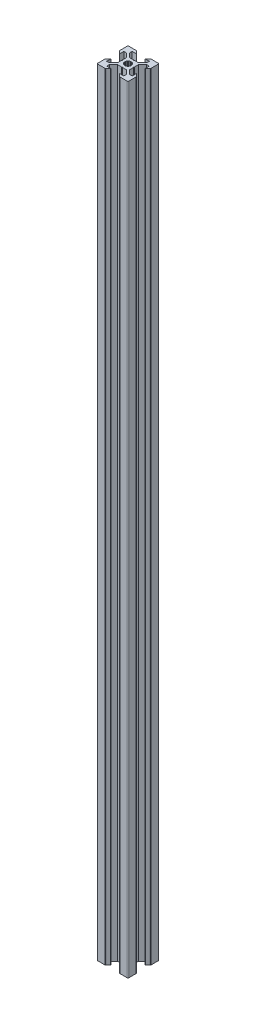
from build123d import *

# Parameters (mm, degrees)
SALIENTE_EXTRUIR1_DEPTH = 500


with BuildPart() as part:
    # Croquis1 → Saliente-Extruir1 (new body)
    with BuildSketch(Plane(origin=(0, 0, 0), x_dir=(1, 0, 0), z_dir=(0, 1, 0))):
        with BuildLine():
            Line((827.4236778, 71.014633494), (827.419784138, 71.054166508))
            Line((827.419784138, 71.054166508), (827.418484267, 71.162420688))
            Line((827.418484267, 71.162420688), (827.418484196, 74.762420877))
            Line((827.418484196, 74.762420877), (827.418484121, 75.762420899))
            ThreePointArc((827.418484121, 75.762420899), (827.564930731, 76.11597429), (827.918484121, 76.262420899))
            Line((827.918484121, 76.262420899), (828.918484173, 76.262420899))
            Line((828.918484173, 76.262420899), (832.587035917, 76.262421281))
            Line((832.587035917, 76.262421281), (832.626738946, 76.261121539))
            Line((832.626738946, 76.261121539), (832.66627196, 76.257227878))
            Line((832.66627196, 76.257227878), (832.705465673, 76.25075697))
            Line((832.705465673, 76.25075697), (832.744152252, 76.241736525))
            Line((832.744152252, 76.241736525), (832.782166034, 76.230205171))
            Line((832.782166034, 76.230205171), (832.81934424, 76.216212285))
            Line((832.81934424, 76.216212285), (832.855527665, 76.199817789))
            Line((832.855527665, 76.199817789), (832.890561368, 76.181091885))
            Line((832.890561368, 76.181091885), (832.924295328, 76.160114761))
            Line((832.924295328, 76.160114761), (832.956585091, 76.136976243))
            Line((832.956585091, 76.136976243), (832.987292389, 76.111775416))
            Line((832.987292389, 76.111775416), (833.016285726, 76.084620192))
            Line((833.016285726, 76.084620192), (834.531857711, 74.569048208))
            Line((834.531857711, 74.569048208), (834.531857711, 74.462421311))
            Line((834.531857711, 74.462421311), (831.918484198, 74.462420944))
            Line((831.918484198, 74.462420944), (831.918484223, 72.823081117))
            Line((831.918484223, 72.823081117), (834.579144475, 70.16242107))
            Line((834.579144475, 70.16242107), (837.213715095, 70.162421031))
            Line((837.213715095, 70.162421031), (837.418484299, 69.957651822))
            Line((837.418484299, 69.957651822), (837.623253509, 70.162421025))
            Line((837.623253509, 70.162421025), (840.257824129, 70.162420986))
            Line((840.257824129, 70.162420986), (842.918484218, 72.823081281))
            Line((842.918484218, 72.823081281), (842.918484194, 74.462421108))
            Line((842.918484194, 74.462421108), (840.305111552, 74.462421165))
            Line((840.305111552, 74.462421165), (840.305111552, 74.569048062))
            Line((840.305111552, 74.569048062), (841.820683537, 76.084620046))
            Line((841.820683537, 76.084620046), (841.849676874, 76.11177527))
            Line((841.849676874, 76.11177527), (841.880384171, 76.136976097))
            Line((841.880384171, 76.136976097), (841.912673935, 76.160114615))
            Line((841.912673935, 76.160114615), (841.946407895, 76.181091739))
            Line((841.946407895, 76.181091739), (841.981441597, 76.199817643))
            Line((841.981441597, 76.199817643), (842.017625023, 76.216212139))
            Line((842.017625023, 76.216212139), (842.054803228, 76.230205025))
            Line((842.054803228, 76.230205025), (842.092817011, 76.241736379))
            Line((842.092817011, 76.241736379), (842.13150359, 76.250756824))
            Line((842.13150359, 76.250756824), (842.170697303, 76.257227732))
            Line((842.170697303, 76.257227732), (842.210230317, 76.261121393))
            Line((842.210230317, 76.261121393), (842.249933345, 76.262421135))
            Line((842.249933345, 76.262421135), (845.918484166, 76.262421152))
            Line((845.918484166, 76.262421152), (846.918484113, 76.262420899))
            ThreePointArc((846.918484113, 76.262420899), (847.272037504, 76.11597429), (847.418484113, 75.762420899))
            Line((847.418484113, 75.762420899), (847.418484676, 71.093869834))
            Line((847.418484676, 71.093869834), (847.417184713, 71.054166625))
            Line((847.417184713, 71.054166625), (847.413291052, 71.014633611))
            Line((847.413291052, 71.014633611), (847.406820144, 70.975439898))
            Line((847.406820144, 70.975439898), (847.397799699, 70.936753319))
            Line((847.397799699, 70.936753319), (847.386268345, 70.898739536))
            Line((847.386268345, 70.898739536), (847.372275459, 70.861561331))
            Line((847.372275459, 70.861561331), (847.355880963, 70.825377905))
            Line((847.355880963, 70.825377905), (847.337155059, 70.790344203))
            Line((847.337155059, 70.790344203), (847.316177935, 70.756610243))
            Line((847.316177935, 70.756610243), (847.293039418, 70.724320479))
            Line((847.293039418, 70.724320479), (847.26783859, 70.693613182))
            Line((847.26783859, 70.693613182), (847.240683366, 70.664619845))
            Line((847.240683366, 70.664619845), (845.725111382, 69.14904786))
            Line((845.725111382, 69.14904786), (845.618484485, 69.14904786))
            Line((845.618484485, 69.14904786), (845.618484322, 71.762420905))
            Line((845.618484322, 71.762420905), (843.979144495, 71.76242093))
            Line((843.979144495, 71.76242093), (841.318484285, 69.101760799))
            Line((841.318484285, 69.101760799), (841.318484245, 66.462288999))
            Line((841.318484245, 66.462288999), (841.118616215, 66.262420975))
            Line((841.118616215, 66.262420975), (841.318484239, 66.062552944))
            Line((841.318484239, 66.062552944), (841.3184842, 63.423081145))
            Line((841.3184842, 63.423081145), (843.979144331, 60.762420934))
            Line((843.979144331, 60.762420934), (845.618484159, 60.76242091))
            Line((845.618484159, 60.76242091), (845.618484631, 63.375794018))
            Line((845.618484631, 63.375794018), (845.725111528, 63.375794018))
            Line((845.725111528, 63.375794018), (847.240683512, 61.860222034))
            Line((847.240683512, 61.860222034), (847.267838736, 61.831228696))
            Line((847.267838736, 61.831228696), (847.293039564, 61.800521399))
            Line((847.293039564, 61.800521399), (847.316178081, 61.768231636))
            Line((847.316178081, 61.768231636), (847.337155205, 61.734497676))
            Line((847.337155205, 61.734497676), (847.355881109, 61.699463973))
            Line((847.355881109, 61.699463973), (847.372275605, 61.663280548))
            Line((847.372275605, 61.663280548), (847.386268491, 61.626102342))
            Line((847.386268491, 61.626102342), (847.397799845, 61.58808856))
            Line((847.397799845, 61.58808856), (847.40682029, 61.549401981))
            Line((847.40682029, 61.549401981), (847.413291198, 61.510208268))
            Line((847.413291198, 61.510208268), (847.417184859, 61.470675254))
            Line((847.417184859, 61.470675254), (847.418484601, 61.430972225))
            Line((847.418484601, 61.430972225), (847.418484113, 57.762420884))
            Line((847.418484113, 57.762420884), (847.418484113, 56.762420907))
            ThreePointArc((847.418484113, 56.762420907), (847.272037504, 56.408867517), (846.918484113, 56.262420907))
            Line((846.918484113, 56.262420907), (845.918484091, 56.262420907))
            Line((845.918484091, 56.262420907), (842.249933271, 56.262420924))
            Line((842.249933271, 56.262420924), (842.210230242, 56.263720666))
            Line((842.210230242, 56.263720666), (842.170697228, 56.267614328))
            Line((842.170697228, 56.267614328), (842.131503515, 56.274085236))
            Line((842.131503515, 56.274085236), (842.092816936, 56.28310568))
            Line((842.092816936, 56.28310568), (842.054803154, 56.294637035))
            Line((842.054803154, 56.294637035), (842.017624948, 56.30862992))
            Line((842.017624948, 56.30862992), (841.981441523, 56.325024417))
            Line((841.981441523, 56.325024417), (841.94640782, 56.343750321))
            Line((841.94640782, 56.343750321), (841.91267386, 56.364727445))
            Line((841.91267386, 56.364727445), (841.880384097, 56.387865962))
            Line((841.880384097, 56.387865962), (841.8496768, 56.41306679))
            Line((841.8496768, 56.41306679), (841.820683462, 56.440222013))
            Line((841.820683462, 56.440222013), (840.305111478, 57.955793998))
            Line((840.305111478, 57.955793998), (840.305111478, 58.062420895))
            Line((840.305111478, 58.062420895), (842.918484119, 58.062420951))
            Line((842.918484119, 58.062420951), (842.918484144, 59.701760779))
            Line((842.918484144, 59.701760779), (840.257824013, 62.362420989))
            Line((840.257824013, 62.362420989), (837.623253392, 62.362421028))
            Line((837.623253392, 62.362421028), (837.418484189, 62.567190238))
            Line((837.418484189, 62.567190238), (837.211510002, 62.362420842))
            Line((837.211510002, 62.362420842), (834.579144359, 62.362421074))
            Line((834.579144359, 62.362421074), (831.918484148, 59.701760943))
            Line((831.918484148, 59.701760943), (831.918484124, 58.062421115))
            Line((831.918484124, 58.062421115), (834.531857636, 58.062420749))
            Line((834.531857636, 58.062420749), (834.531857636, 57.955793852))
            Line((834.531857636, 57.955793852), (833.016285651, 56.440221867))
            Line((833.016285651, 56.440221867), (832.987292314, 56.413066643))
            Line((832.987292314, 56.413066643), (832.956585017, 56.387865816))
            Line((832.956585017, 56.387865816), (832.924295253, 56.364727299))
            Line((832.924295253, 56.364727299), (832.890561293, 56.343750175))
            Line((832.890561293, 56.343750175), (832.855527591, 56.325024271))
            Line((832.855527591, 56.325024271), (832.819344165, 56.308629774))
            Line((832.819344165, 56.308629774), (832.78216596, 56.294636889))
            Line((832.78216596, 56.294636889), (832.744152177, 56.283105534))
            Line((832.744152177, 56.283105534), (832.705465598, 56.27408509))
            Line((832.705465598, 56.27408509), (832.666271885, 56.267614182))
            Line((832.666271885, 56.267614182), (832.626738871, 56.26372052))
            Line((832.626738871, 56.26372052), (832.587035843, 56.262420778))
            Line((832.587035843, 56.262420778), (827.918484121, 56.262420907))
            ThreePointArc((827.918484121, 56.262420907), (827.564930731, 56.408867517), (827.418484121, 56.762420907))
            Line((827.418484121, 56.762420907), (827.418484121, 57.762421182))
            Line((827.418484121, 57.762421182), (827.418484413, 61.362420692))
            Line((827.418484413, 61.362420692), (827.419784284, 61.470675137))
            Line((827.419784284, 61.470675137), (827.423677946, 61.510208151))
            Line((827.423677946, 61.510208151), (827.430148853, 61.549401865))
            Line((827.430148853, 61.549401865), (827.439169298, 61.588088443))
            Line((827.439169298, 61.588088443), (827.450700653, 61.626102226))
            Line((827.450700653, 61.626102226), (827.464693538, 61.663280431))
            Line((827.464693538, 61.663280431), (827.481088034, 61.699463857))
            Line((827.481088034, 61.699463857), (827.499813938, 61.73449756))
            Line((827.499813938, 61.73449756), (827.520791063, 61.76823152))
            Line((827.520791063, 61.76823152), (827.54392958, 61.800521283))
            Line((827.54392958, 61.800521283), (827.569130407, 61.83122858))
            Line((827.569130407, 61.83122858), (827.596285631, 61.860221918))
            Line((827.596285631, 61.860221918), (829.111857616, 63.375793902))
            Line((829.111857616, 63.375793902), (829.218484512, 63.375793902))
            Line((829.218484512, 63.375793902), (829.218484165, 60.762421154))
            Line((829.218484165, 60.762421154), (830.857823993, 60.76242113))
            Line((830.857823993, 60.76242113), (833.518484203, 63.423081261))
            Line((833.518484203, 63.423081261), (833.518484243, 66.06255306))
            Line((833.518484243, 66.06255306), (833.718352273, 66.262421085))
            Line((833.718352273, 66.262421085), (833.518484248, 66.462289116))
            Line((833.518484248, 66.462289116), (833.518484288, 69.101760915))
            Line((833.518484288, 69.101760915), (830.857824157, 71.762421125))
            Line((830.857824157, 71.762421125), (829.218484329, 71.76242115))
            Line((829.218484329, 71.76242115), (829.218484366, 69.149047744))
            Line((829.218484366, 69.149047744), (829.11185747, 69.149047744))
            Line((829.11185747, 69.149047744), (827.596285485, 70.664619728))
            Line((827.596285485, 70.664619728), (827.569130261, 70.693613066))
            Line((827.569130261, 70.693613066), (827.543929434, 70.724320363))
            Line((827.543929434, 70.724320363), (827.520790917, 70.756610126))
            Line((827.520790917, 70.756610126), (827.499813792, 70.790344086))
            Line((827.499813792, 70.790344086), (827.481087888, 70.825377789))
            Line((827.481087888, 70.825377789), (827.464693392, 70.861561215))
            Line((827.464693392, 70.861561215), (827.450700507, 70.89873942))
            Line((827.450700507, 70.89873942), (827.439169152, 70.936753202))
            Line((827.439169152, 70.936753202), (827.430148707, 70.975439781))
            Line((827.430148707, 70.975439781), (827.4236778, 71.014633494))
        make_face()
        Polygon((835.599830933, 65.212420993), (835.933560041, 64.777496752), (836.368484281, 64.443767645), (836.874964286, 64.233976757), (837.418484281, 64.162420993), (837.962004276, 64.233976757), (838.468484281, 64.443767645), (838.903408522, 64.777496752), (839.237137629, 65.212420993), (839.446928516, 65.718900998), (839.518484281, 66.262420993), (839.446928516, 66.805940987), (839.237137629, 67.312420993), (838.903408522, 67.747345233), (838.468484281, 68.08107434), (837.962004276, 68.290865228), (837.418484281, 68.362420993), (836.874964286, 68.290865228), (836.368484281, 68.08107434), (835.933560041, 67.747345233), (835.599830933, 67.312420993), (835.390040046, 66.805940987), (835.318484281, 66.262420993), (835.390040046, 65.718900998), align=None, mode=Mode.SUBTRACT)
    extrude(amount=SALIENTE_EXTRUIR1_DEPTH)


solid = part.part
